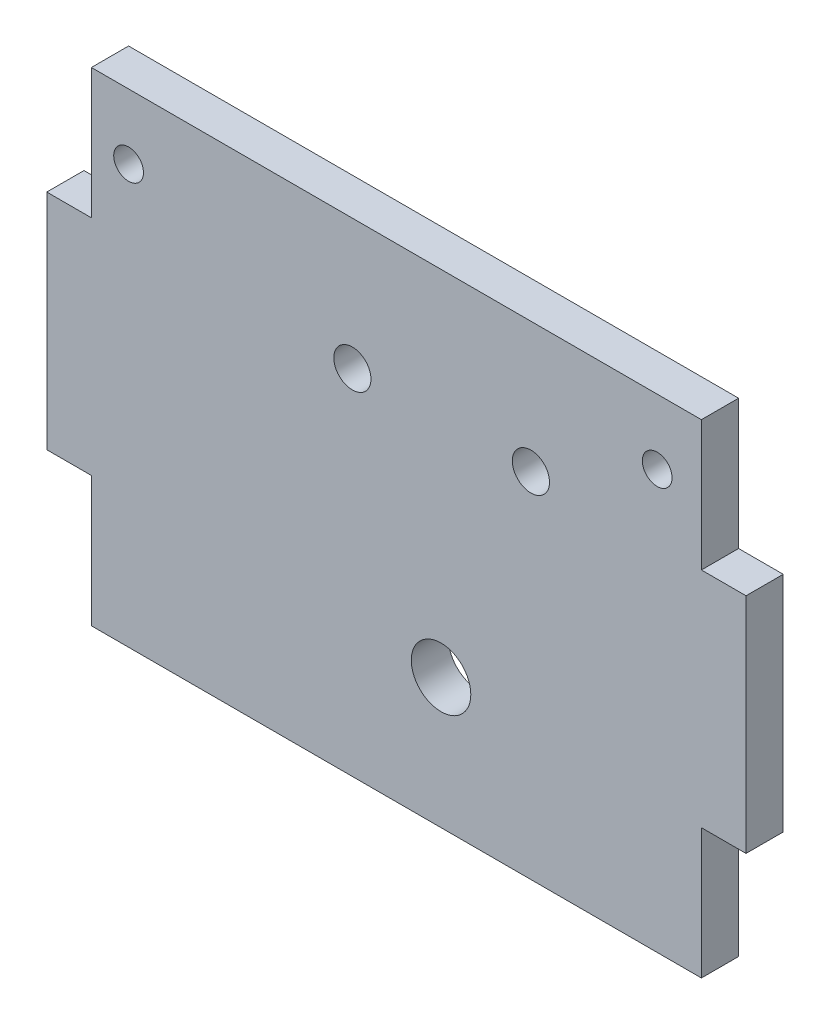
from build123d import *

# Parameters (mm, degrees)
SKETCH2_W            = 50
SKETCH2_H            = 65
SKETCH2_R            = 2
SKETCH2_R_2          = 4
BOSS_EXTRUDE1_DEPTH  = 5
SKETCH4_W            = 21
SKETCH4_H            = 65
BOSS_EXTRUDE3_DEPTH  = 5
SKETCH5_W            = 1
SKETCH5_H            = 65
BOSS_EXTRUDE4_DEPTH  = 5
BOSS_EXTRUDE5_DEPTH  = 5
SKETCH7_R            = 2
CUT_EXTRUDE1_DEPTH   = 59
SKETCH8_R            = 1.5
CUT_EXTRUDE2_DEPTH   = 10
SKETCH9_R            = 2
CUT_EXTRUDE3_DEPTH   = 10
SKETCH10_R           = 2.5
CUT_EXTRUDE4_DEPTH   = 10
SKETCH11_R           = 2.5
CUT_EXTRUDE5_DEPTH   = 10
SKETCH11_3_R         = 2.5
BOSS_EXTRUDE6_DEPTH  = 5
SKETCH12_W           = 5
SKETCH12_H           = 17.5
BOSS_EXTRUDE7_DEPTH  = 10
SKETCH13_W           = 5
SKETCH13_H           = 30
BOSS_EXTRUDE8_DEPTH  = 10
SKETCH14_W           = 5
SKETCH14_H           = 17.5
BOSS_EXTRUDE9_DEPTH  = 10
SKETCH15_R           = 2
BOSS_EXTRUDE10_DEPTH = 5
SKETCH15_3_R         = 2
CUT_EXTRUDE6_DEPTH   = 10
SKETCH16_R           = 2.5
BOSS_EXTRUDE11_DEPTH = 5
CUT_EXTRUDE7_DEPTH   = 10


with BuildPart() as part:
    # Sketch2 → Boss-Extrude1 (new body)
    with BuildSketch(Plane.XY):
        with Locations((25, 32.5)):
            Rectangle(SKETCH2_W, SKETCH2_H)
        with Locations((25, 59.5)):
            Circle(SKETCH2_R, mode=Mode.SUBTRACT)
        with Locations((13, 47.5)):
            Circle(SKETCH2_R, mode=Mode.SUBTRACT)
        with Locations((37, 47.5)):
            Circle(SKETCH2_R, mode=Mode.SUBTRACT)
        with Locations((25, 17.5)):
            Circle(SKETCH2_R_2, mode=Mode.SUBTRACT)
    extrude(amount=BOSS_EXTRUDE1_DEPTH)

    # Sketch4 → Boss-Extrude3 (add)
    with BuildSketch(Plane.XY.offset(5)):
        with Locations((-10.5, 32.5)):
            Rectangle(SKETCH4_W, SKETCH4_H)
    extrude(amount=-BOSS_EXTRUDE3_DEPTH)

    # Sketch5 → Boss-Extrude4 (add)
    with BuildSketch(Plane(origin=(0, 0, 0), x_dir=(-1, 0, 0), z_dir=(0, 0, -1))):
        with Locations((21.5, 32.5)):
            Rectangle(SKETCH5_W, SKETCH5_H)
    extrude(amount=-BOSS_EXTRUDE4_DEPTH)

    # Sketch6 → Boss-Extrude5 (add)
    with BuildSketch(Plane.XY.offset(5)):
        Polygon((-22, 17.5), (-22, 32.5), (-22, 47.5), (-28, 47.5), (-28, 17.5), align=None)
        Polygon((56, 17.5), (56, 47.5), (50, 47.5), (50, 32.5), (50, 17.5), align=None)
    extrude(amount=-BOSS_EXTRUDE5_DEPTH)

    # Sketch7 → Cut-Extrude1 (cut)
    with BuildSketch(Plane.XY.offset(5)):
        with Locations((25, 35.5)):
            Circle(SKETCH7_R)
    extrude(amount=-CUT_EXTRUDE1_DEPTH, mode=Mode.SUBTRACT)

    # Sketch8 → Cut-Extrude2 (cut)
    with BuildSketch(Plane.XY.offset(5)):
        with Locations((-17, 56.25)):
            Circle(SKETCH8_R)
        with Locations((44.055639416, 56.25)):
            Circle(SKETCH8_R)
    extrude(amount=-CUT_EXTRUDE2_DEPTH, mode=Mode.SUBTRACT)

    # Sketch9 → Cut-Extrude3 (cut)
    with BuildSketch(Plane.XY.offset(5)):
        with Locations((-17, 56.25)):
            Circle(SKETCH9_R)
        with Locations((44.055639416, 56.25)):
            Circle(SKETCH9_R)
    extrude(amount=-CUT_EXTRUDE3_DEPTH, mode=Mode.SUBTRACT)

    # Sketch10 → Cut-Extrude4 (cut)
    with BuildSketch(Plane.XY.offset(5)):
        with Locations((25, 59.5)):
            Circle(SKETCH10_R)
        with Locations((25, 35.5)):
            Circle(SKETCH10_R)
        with Locations((13, 47.5)):
            Circle(SKETCH10_R)
        with Locations((37, 47.5)):
            Circle(SKETCH10_R)
    extrude(amount=-CUT_EXTRUDE4_DEPTH, mode=Mode.SUBTRACT)

    # Sketch11 → Cut-Extrude5 (cut)
    with BuildSketch(Plane.XY.offset(5)):
        with Locations((6.5, 47.5)):
            Circle(SKETCH11_R)
        with Locations((43.663505444, 47.5)):
            Circle(SKETCH11_R)
    extrude(amount=-CUT_EXTRUDE5_DEPTH, mode=Mode.SUBTRACT)

    # Sketch11_3 → Boss-Extrude6 (add)
    with BuildSketch(Plane.XY.offset(5)):
        with Locations((25, 59.5)):
            Circle(SKETCH11_3_R)
        with BuildLine():
            Line((10.5, 47.5), (13, 47.5))
            Line((13, 47.5), (15.5, 47.5))
            ThreePointArc((15.5, 47.5), (13, 50), (10.5, 47.5))
        make_face()
        with BuildLine():
            Line((15.5, 47.5), (13, 47.5))
            Line((13, 47.5), (10.5, 47.5))
            ThreePointArc((10.5, 47.5), (13, 45), (15.5, 47.5))
        make_face()
        with BuildLine():
            ThreePointArc((39.5, 47.5), (37, 50), (34.5, 47.5))
            Line((34.5, 47.5), (37, 47.5))
            Line((37, 47.5), (39.5, 47.5))
        make_face()
        with BuildLine():
            Line((37, 47.5), (34.5, 47.5))
            ThreePointArc((34.5, 47.5), (37, 45), (39.5, 47.5))
            Line((39.5, 47.5), (37, 47.5))
        make_face()
        with Locations((25, 35.5)):
            Circle(SKETCH11_3_R)
    extrude(amount=-BOSS_EXTRUDE6_DEPTH)

    # Sketch12 → Boss-Extrude7 (add)
    with BuildSketch(Plane(origin=(50, 0, 0), x_dir=(0, 0, -1), z_dir=(1, 0, 0))):
        with Locations((-2.5, 56.25)):
            Rectangle(SKETCH12_W, SKETCH12_H)
    extrude(amount=BOSS_EXTRUDE7_DEPTH)

    # Sketch13 → Boss-Extrude8 (add)
    with BuildSketch(Plane(origin=(56, 0, 0), x_dir=(0, 0, -1), z_dir=(1, 0, 0))):
        with Locations((-2.5, 32.5)):
            Rectangle(SKETCH13_W, SKETCH13_H)
    extrude(amount=BOSS_EXTRUDE8_DEPTH)

    # Sketch14 → Boss-Extrude9 (add)
    with BuildSketch(Plane(origin=(50, 0, 0), x_dir=(0, 0, -1), z_dir=(1, 0, 0))):
        with Locations((-2.5, 8.75)):
            Rectangle(SKETCH14_W, SKETCH14_H)
    extrude(amount=BOSS_EXTRUDE9_DEPTH)

    # Sketch15 → Boss-Extrude10 (add)
    with BuildSketch(Plane.XY.offset(5)):
        with Locations((54.055639416, 56.25)):
            Circle(SKETCH15_R)
        with Locations((44.055639416, 56.25)):
            Circle(SKETCH15_R)
    extrude(amount=-BOSS_EXTRUDE10_DEPTH)

    # Sketch15_3 → Cut-Extrude6 (cut)
    with BuildSketch(Plane.XY.offset(5)):
        with Locations((54.055639416, 56.25)):
            Circle(SKETCH15_3_R)
    extrude(amount=-CUT_EXTRUDE6_DEPTH, mode=Mode.SUBTRACT)

    # Sketch16 → Boss-Extrude11 (add)
    with BuildSketch(Plane.XY.offset(5)):
        with Locations((6.5, 47.5)):
            Circle(SKETCH16_R)
        with Locations((13.081752722, 47.5)):
            Circle(SKETCH16_R)
        with Locations((37.081752722, 47.5)):
            Circle(SKETCH16_R)
        with Locations((43.663505444, 47.5)):
            Circle(SKETCH16_R)
    extrude(amount=-BOSS_EXTRUDE11_DEPTH)

    # Sketch16_3 → Cut-Extrude7 (cut)
    with BuildSketch(Plane.XY.offset(5)):
        with BuildLine():
            Line((10.581752722, 47.5), (13.081752722, 47.5))
            Line((13.081752722, 47.5), (15.581752722, 47.5))
            ThreePointArc((15.581752722, 47.5), (13.081752722, 50), (10.581752722, 47.5))
        make_face()
        with BuildLine():
            Line((15.581752722, 47.5), (13.081752722, 47.5))
            Line((13.081752722, 47.5), (10.581752722, 47.5))
            ThreePointArc((10.581752722, 47.5), (13.081752722, 45), (15.581752722, 47.5))
        make_face()
        with BuildLine():
            ThreePointArc((39.581752722, 47.5), (37.081752722, 50), (34.581752722, 47.5))
            Line((34.581752722, 47.5), (37.081752722, 47.5))
            Line((37.081752722, 47.5), (39.581752722, 47.5))
        make_face()
        with BuildLine():
            Line((37.081752722, 47.5), (34.581752722, 47.5))
            ThreePointArc((34.581752722, 47.5), (37.081752722, 45), (39.581752722, 47.5))
            Line((39.581752722, 47.5), (37.081752722, 47.5))
        make_face()
    extrude(amount=-CUT_EXTRUDE7_DEPTH, mode=Mode.SUBTRACT)


solid = part.part
